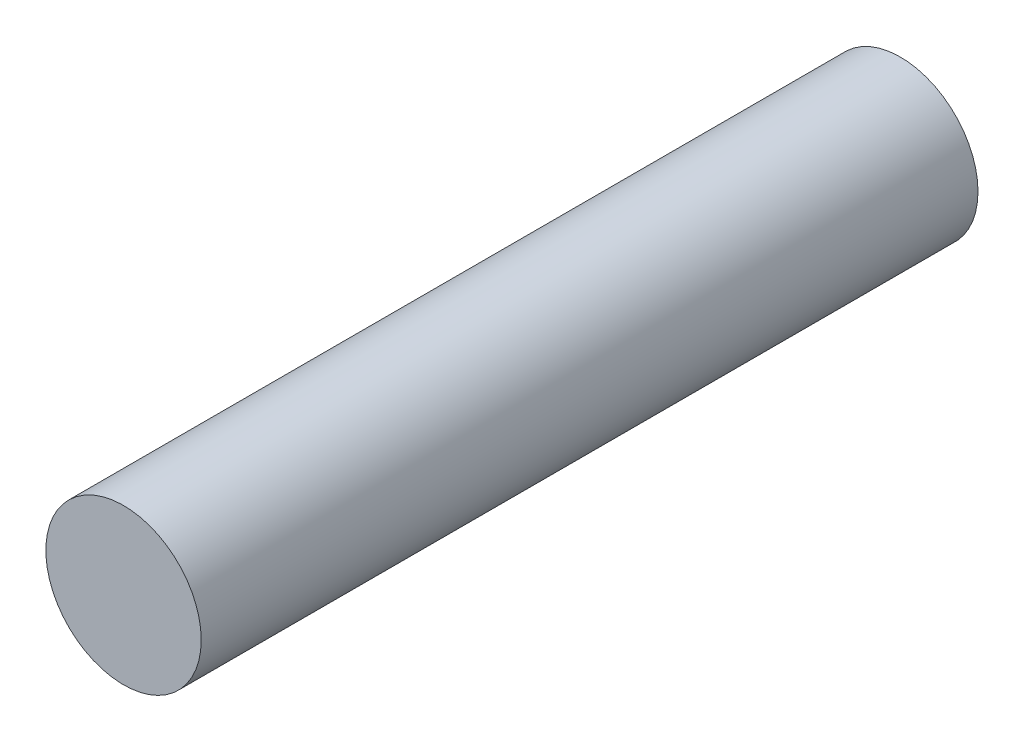
from build123d import *

# Parameters (mm, degrees)
BOSS_EXTRUDE1_DEPTH      = 127
BOSS_EXTRUDE1_DEPTH_BACK = 127
SKETCH1_R                = 25.4


with BuildPart() as part:
    # Sketch1 → Boss-Extrude1 (new, two sides: drawn at the far end of the back side and taken through both)
    with BuildSketch(Plane.XY.offset(-BOSS_EXTRUDE1_DEPTH_BACK)):
        Circle(SKETCH1_R)
    extrude(amount=BOSS_EXTRUDE1_DEPTH + BOSS_EXTRUDE1_DEPTH_BACK)


solid = part.part
